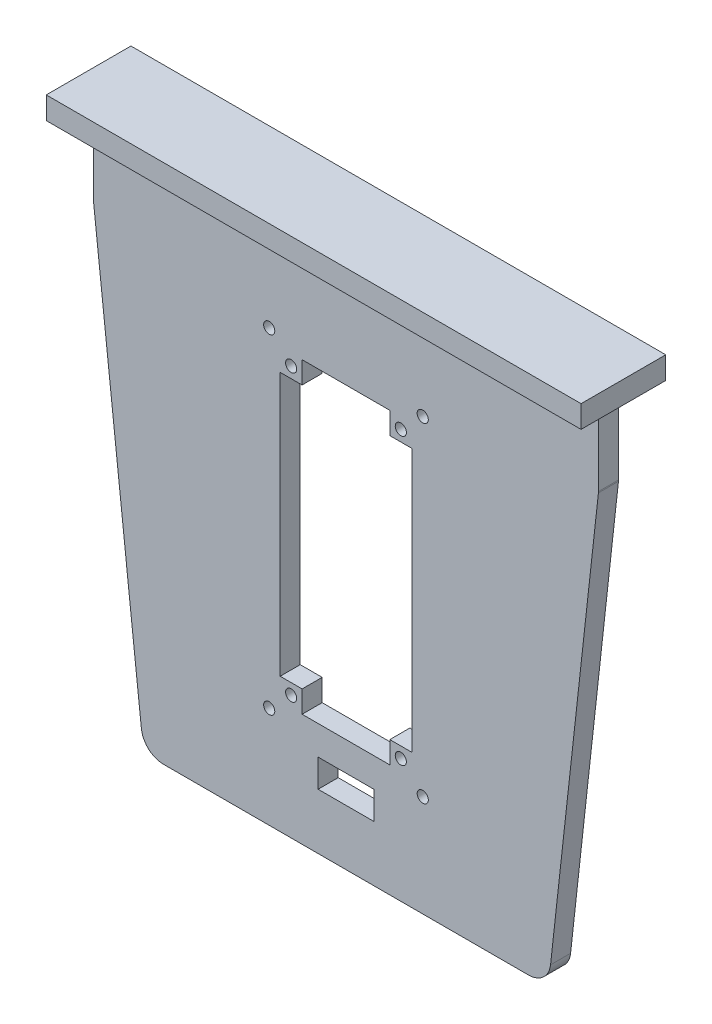
from build123d import *

# Parameters (mm, degrees)
BOSS_EXTRUDE1_DEPTH = 4.572
SKETCH3_W           = 115.1315452
SKETCH3_H           = 4.572
BOSS_EXTRUDE2_DEPTH = 17.78
FILLET1_R           = 2.54
SKETCH4_W           = 121.92
SKETCH4_H           = 19.304
BOSS_EXTRUDE4_DEPTH = 5.08
SKETCH5_W           = 12.7
SKETCH5_H           = 6.35
CUT_EXTRUDE1_DEPTH  = 5.08
SKETCH6_R           = 1.27
CUT_EXTRUDE2_DEPTH  = 6.35


with BuildPart() as part:
    # Sketch2 → Boss-Extrude1 (new body)
    with BuildSketch(Plane(origin=(0, 0, 0), x_dir=(-1, 0, 0), z_dir=(0, 0, -1))):
        with BuildLine():
            Line((-62.487415839, 48.848476089), (52.644129361, 48.848476089))
            Line((52.644129361, 48.848476089), (41.713156468, -49.932022311))
            ThreePointArc((41.713156468, -49.932022311), (40.052782988, -53.157778108), (36.663977171, -54.453284069))
            Line((36.663977171, -54.453284069), (-46.507263649, -54.453284069))
            ThreePointArc((-46.507263649, -54.453284069), (-49.896069466, -53.157778108), (-51.556442946, -49.932022311))
            Line((-51.556442946, -49.932022311), (-62.487415839, 48.848476089))
        make_face()
    extrude(amount=BOSS_EXTRUDE1_DEPTH)

    # Sketch3 → Boss-Extrude2 (add)
    with BuildSketch(Plane(origin=(0, 48.848476089, 0), x_dir=(1, 0, 0), z_dir=(0, 1, 0))):
        with Locations((4.921643239, 2.286)):
            Rectangle(SKETCH3_W, SKETCH3_H)
    extrude(amount=BOSS_EXTRUDE2_DEPTH)

    # Fillet1
    fillet1_edges = [part.edges().sort_by_distance(p)[0] for p in [
        (62.487415839, 48.848476089, -2.286),
        (-52.644129361, 48.848476089, -2.286),
    ]]
    fillet(fillet1_edges, radius=FILLET1_R)

    # Sketch4 → Boss-Extrude4 (add)
    with BuildSketch(Plane(origin=(0, 66.628476089, 0), x_dir=(1, 0, 0), z_dir=(0, 1, 0))):
        with Locations((4.921643239, 2.286)):
            Rectangle(SKETCH4_W, SKETCH4_H)
    extrude(amount=BOSS_EXTRUDE4_DEPTH)

    # Sketch5 → Cut-Extrude1 (cut)
    with BuildSketch(Plane(origin=(0, 0, -4.572), x_dir=(-1, 0, 0), z_dir=(0, 0, -1))):
        with Locations((-4.921643239, -38.578284069)):
            Rectangle(SKETCH5_W, SKETCH5_H)
    extrude(amount=-CUT_EXTRUDE1_DEPTH, mode=Mode.SUBTRACT)

    # Sketch6 → Cut-Extrude2 (cut)
    with BuildSketch(Plane(origin=(0, 0, -4.572), x_dir=(-1, 0, 0), z_dir=(0, 0, -1))):
        Polygon((10.078356761, -23.771523911), (10.078356761, 36.228476089), (5.078356761, 36.228476089), (5.078356761, 41.228476089), (-14.921643239, 41.228476089), (-14.921643239, 36.228476089), (-19.921643239, 36.228476089), (-19.921643239, -23.771523911), (-14.921643239, -23.771523911), (-14.921643239, -28.771523911), (5.078356761, -28.771523911), (5.078356761, -23.771523911), align=None)
        with Locations((-17.421643239, 38.728476089)):
            Circle(SKETCH6_R)
        with Locations((7.578356761, -26.271523911)):
            Circle(SKETCH6_R)
        with Locations((-17.421643239, -26.271523911)):
            Circle(SKETCH6_R)
        with Locations((-22.421643239, -31.311523911)):
            Circle(SKETCH6_R)
        with Locations((12.578356761, -31.311523911)):
            Circle(SKETCH6_R)
        with Locations((12.578356761, 43.768476089)):
            Circle(SKETCH6_R)
        with Locations((-22.421643239, 43.768476089)):
            Circle(SKETCH6_R)
        with Locations((7.578356761, 38.728476089)):
            Circle(SKETCH6_R)
    extrude(amount=-CUT_EXTRUDE2_DEPTH, mode=Mode.SUBTRACT)


solid = part.part
